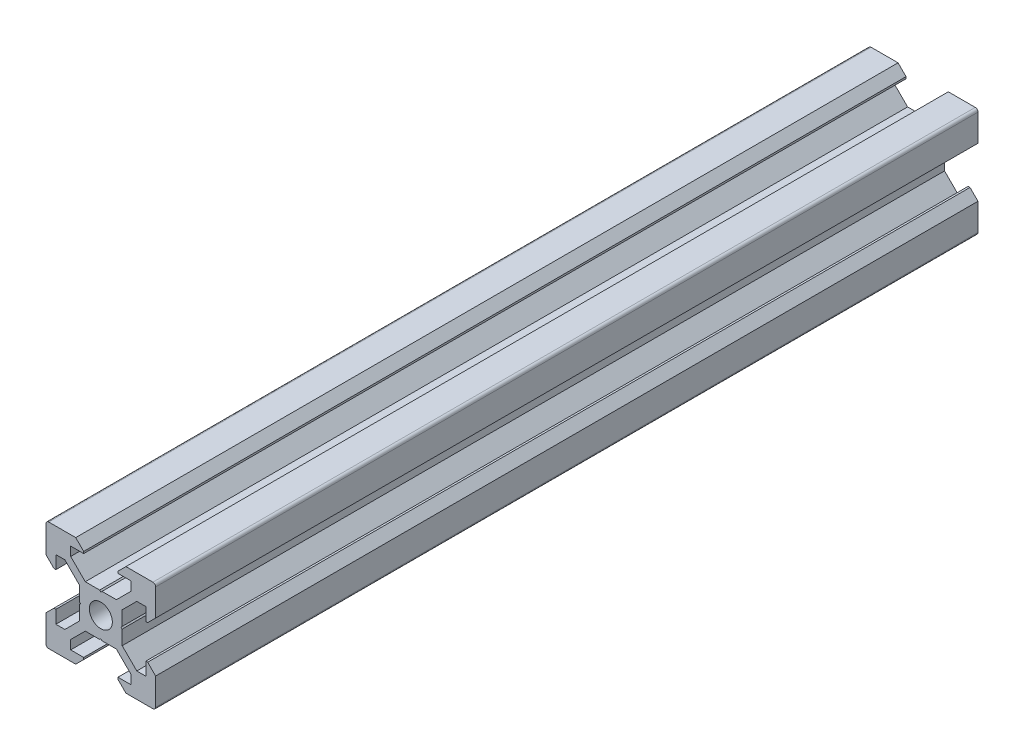
from build123d import *

# Parameters (mm, degrees)
SKETCH1_R           = 2.1
BOSS_EXTRUDE1_DEPTH = 150


with BuildPart() as part:
    # Sketch1 → Boss-Extrude1 (new body)
    with BuildSketch(Plane.XY):
        with BuildLine():
            Line((4.58, -10), (9.5, -10))
            ThreePointArc((9.5, -10), (9.853553391, -9.853553391), (10, -9.5))
            Line((10, -9.5), (10, -4.58))
            Line((10, -4.58), (8.545, -3.125))
            Line((8.545, -3.125), (8.2, -3.125))
            Line((8.2, -3.125), (8.2, -5.5))
            Line((8.2, -5.5), (6.560660172, -5.5))
            Line((6.560660172, -5.5), (3.9, -2.839339828))
            Line((3.9, -2.839339828), (3.9, -0.21))
            Line((3.9, -0.21), (3.69, 0))
            Line((3.69, 0), (3.9, 0.21))
            Line((3.9, 0.21), (3.9, 2.839339828))
            Line((3.9, 2.839339828), (6.560660172, 5.5))
            Line((6.560660172, 5.5), (8.2, 5.5))
            Line((8.2, 5.5), (8.2, 3.125))
            Line((8.2, 3.125), (8.545, 3.125))
            Line((8.545, 3.125), (10, 4.58))
            Line((10, 4.58), (10, 9.5))
            ThreePointArc((10, 9.5), (9.853553391, 9.853553391), (9.5, 10))
            Line((9.5, 10), (4.58, 10))
            Line((4.58, 10), (3.125, 8.545))
            Line((3.125, 8.545), (3.125, 8.2))
            Line((3.125, 8.2), (5.5, 8.2))
            Line((5.5, 8.2), (5.5, 6.560660172))
            Line((5.5, 6.560660172), (2.839339828, 3.9))
            Line((2.839339828, 3.9), (0.21, 3.9))
            Line((0.21, 3.9), (0, 3.69))
            Line((0, 3.69), (-0.21, 3.9))
            Line((-0.21, 3.9), (-2.839339828, 3.9))
            Line((-2.839339828, 3.9), (-5.5, 6.560660172))
            Line((-5.5, 6.560660172), (-5.5, 8.2))
            Line((-5.5, 8.2), (-3.125, 8.2))
            Line((-3.125, 8.2), (-3.125, 8.545))
            Line((-3.125, 8.545), (-4.58, 10))
            Line((-4.58, 10), (-9.5, 10))
            ThreePointArc((-9.5, 10), (-9.853553391, 9.853553391), (-10, 9.5))
            Line((-10, 9.5), (-10, 4.58))
            Line((-10, 4.58), (-8.545, 3.125))
            Line((-8.545, 3.125), (-8.2, 3.125))
            Line((-8.2, 3.125), (-8.2, 5.5))
            Line((-8.2, 5.5), (-6.560660172, 5.5))
            Line((-6.560660172, 5.5), (-3.9, 2.839339828))
            Line((-3.9, 2.839339828), (-3.9, 0.21))
            Line((-3.9, 0.21), (-3.69, 0))
            Line((-3.69, 0), (-3.9, -0.21))
            Line((-3.9, -0.21), (-3.9, -2.839339828))
            Line((-3.9, -2.839339828), (-6.560660172, -5.5))
            Line((-6.560660172, -5.5), (-8.2, -5.5))
            Line((-8.2, -5.5), (-8.2, -3.125))
            Line((-8.2, -3.125), (-8.545, -3.125))
            Line((-8.545, -3.125), (-10, -4.58))
            Line((-10, -4.58), (-10, -9.5))
            ThreePointArc((-10, -9.5), (-9.853553391, -9.853553391), (-9.5, -10))
            Line((-9.5, -10), (-4.58, -10))
            Line((-4.58, -10), (-3.125, -8.545))
            Line((-3.125, -8.545), (-3.125, -8.2))
            Line((-3.125, -8.2), (-5.5, -8.2))
            Line((-5.5, -8.2), (-5.5, -6.560660172))
            Line((-5.5, -6.560660172), (-2.839339828, -3.9))
            Line((-2.839339828, -3.9), (-0.21, -3.9))
            Line((-0.21, -3.9), (0, -3.69))
            Line((0, -3.69), (0.21, -3.9))
            Line((0.21, -3.9), (2.839339828, -3.9))
            Line((2.839339828, -3.9), (5.5, -6.560660172))
            Line((5.5, -6.560660172), (5.5, -8.2))
            Line((5.5, -8.2), (3.125, -8.2))
            Line((3.125, -8.2), (3.125, -8.545))
            Line((3.125, -8.545), (4.58, -10))
        make_face()
        Circle(SKETCH1_R, mode=Mode.SUBTRACT)
    extrude(amount=BOSS_EXTRUDE1_DEPTH)


solid = part.part
